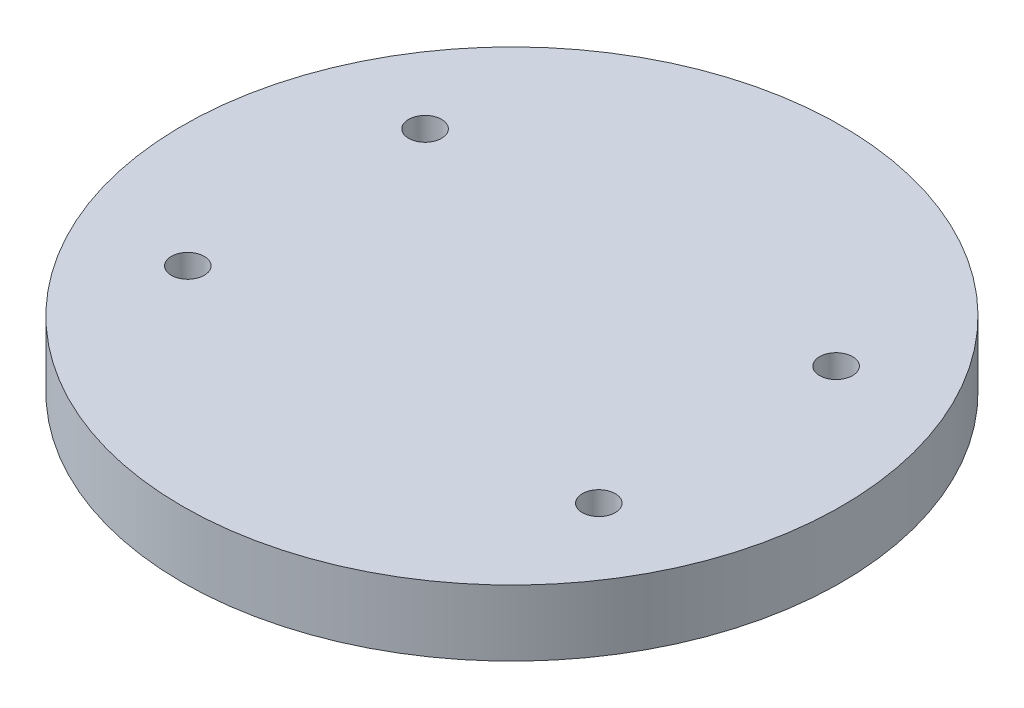
from build123d import *

# Parameters (mm, degrees)
SKETCH2_R               = 50
SKETCH2_R_2             = 2.5
BOSS_EXTRUDE1_DEPTH     = 10
SKETCH3_R               = 12.4125
BOSS_EXTRUDE2_DEPTH     = 20
SKETCH4_R               = 2.5
CUT_EXTRUDE1_DEPTH      = 51
CUT_EXTRUDE1_DEPTH_BACK = 51


with BuildPart() as part:
    # Sketch2 → Boss-Extrude1 (new body)
    with BuildSketch(Plane(origin=(0, 0, 0), x_dir=(1, 0, 0), z_dir=(0, 1, 0))):
        Circle(SKETCH2_R)
        with Locations((-31.176914536, 18)):
            Circle(SKETCH2_R_2, mode=Mode.SUBTRACT)
        with Locations((-31.176914536, -18)):
            Circle(SKETCH2_R_2, mode=Mode.SUBTRACT)
        with Locations((31.176914536, 18)):
            Circle(SKETCH2_R_2, mode=Mode.SUBTRACT)
        with Locations((31.176914536, -18)):
            Circle(SKETCH2_R_2, mode=Mode.SUBTRACT)
    extrude(amount=BOSS_EXTRUDE1_DEPTH)

    # Sketch3 → Boss-Extrude2 (add)
    with BuildSketch(Plane.XZ):
        Circle(SKETCH3_R)
    extrude(amount=BOSS_EXTRUDE2_DEPTH)

    # Sketch4 → Cut-Extrude1 (cut, two sides)
    with BuildSketch(Plane.XY) as cut_extrude1_sk:
        with Locations((0, -10)):
            Circle(SKETCH4_R)
    extrude(amount=CUT_EXTRUDE1_DEPTH, mode=Mode.SUBTRACT)
    extrude(cut_extrude1_sk.sketch, amount=-CUT_EXTRUDE1_DEPTH_BACK, mode=Mode.SUBTRACT)


solid = part.part
